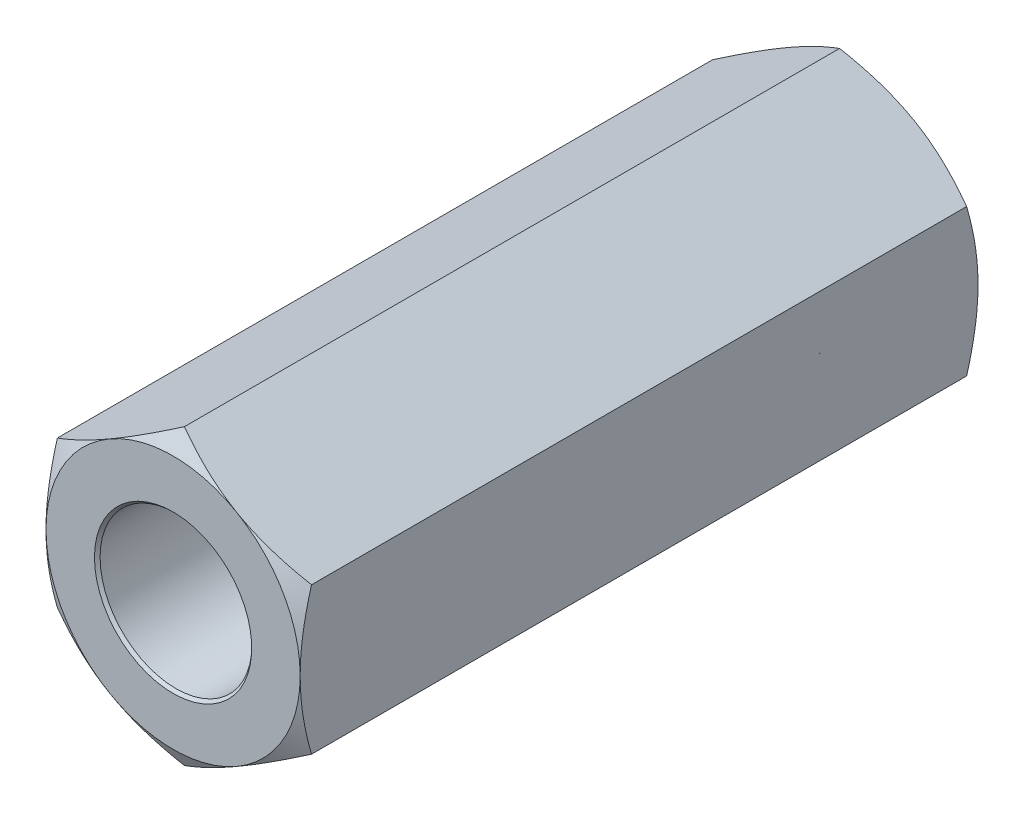
from build123d import *

# Parameters (mm, degrees)
EXTRUDE1_DEPTH          = 6.35
EXTRUDE1_DEPTH_BACK     = 6.35
SKETCH1_R               = 1.4224
SKETCH8_OUTSIDE_W       = 58.916
SKETCH8_OUTSIDE_H       = 59.654
SKETCH8_OUTSIDE_R       = 2.38125
EXTRUDE4_DEPTH          = 14.210632851
EXTRUDE4_DRAFT          = -60
MIRROR1_COPY_1_SKETCH_W = 58.916
MIRROR1_COPY_1_SKETCH_H = 59.654
MIRROR1_COPY_1_SKETCH_R = 2.38125
MIRROR1_COPY_1_DEPTH    = 14.210632851
MIRROR1_COPY_1_DRAFT    = -60


with BuildPart() as part:
    # Sketch1 → Extrude1 (new, two sides: drawn at the far end of the back side and taken through both)
    with BuildSketch(Plane.XY.offset(-EXTRUDE1_DEPTH_BACK)):
        Polygon((0, 2.749630657), (-2.38125, 1.374815329), (-2.38125, -1.374815329), (0, -2.749630657), (2.38125, -1.374815329), (2.38125, 1.374815329), align=None)
        Circle(SKETCH1_R, mode=Mode.SUBTRACT)
    extrude(amount=EXTRUDE1_DEPTH + EXTRUDE1_DEPTH_BACK)

    # Extrude3 cone 1 section (through the dimple's axis) → Extrude3 (revolve, cut)
    with BuildSketch(Plane(origin=(0, 0, -6.35), x_dir=(0, 1, 0), z_dir=(1, 0, 0))):
        Polygon((0, 0), (1.4732, 0), (0, 1.579813584), align=None)
    extrude3 = revolve(axis=Axis((0, 0, -6.35), (0, 0, 1)), mode=Mode.SUBTRACT)


with BuildPart() as extrude4_tool:
    # Sketch8 outside → Extrude4 (with draft: the straight prism first)
    with BuildSketch(Plane(origin=(0, 0, -6.35), x_dir=(-1, 0, 0), z_dir=(0, 0, -1))):
        Rectangle(SKETCH8_OUTSIDE_W, SKETCH8_OUTSIDE_H)
        Circle(SKETCH8_OUTSIDE_R, mode=Mode.SUBTRACT)
    extrude(amount=-EXTRUDE4_DEPTH)
    # Extrude4: the draft: its side faces are tilted about the plane it starts from
    extrude4_sides = [extrude4_tool.faces().sort_by_distance(p)[0] for p in [
        (0, -29.827, 0.755316425),
        (-29.458, 0, 0.755316425),
        (0, 29.827, 0.755316425),
        (29.458, 0, 0.755316425),
        (2.38125, 0, 0.755316425),
    ]]
    draft(extrude4_sides, Plane(origin=(0, 0, -6.35), x_dir=(-1, 0, 0), z_dir=(0, 0, -1)), EXTRUDE4_DRAFT)


with BuildPart() as part_1:
    add(part.part)

    # Extrude4: cut by extrude4_tool
    add(extrude4_tool.part, mode=Mode.SUBTRACT)

    # Mirror1: Extrude3 across plane
    add(extrude3.mirror(Plane.XY), mode=Mode.SUBTRACT)


with BuildPart() as mirror1_copy_1_tool:
    # Mirror1 copy 1 sketch → Mirror1 copy 1 (with draft: the straight prism first)
    with BuildSketch(Plane(origin=(0, 0, 6.35), x_dir=(-1, 0, 0), z_dir=(0, 0, 1))):
        Rectangle(MIRROR1_COPY_1_SKETCH_W, MIRROR1_COPY_1_SKETCH_H)
        Circle(MIRROR1_COPY_1_SKETCH_R, mode=Mode.SUBTRACT)
    extrude(amount=-MIRROR1_COPY_1_DEPTH)
    # Mirror1 copy 1: the draft: its side faces are tilted about the plane it starts from
    mirror1_copy_1_sides = [mirror1_copy_1_tool.faces().sort_by_distance(p)[0] for p in [
        (0, -29.827, -0.755316425),
        (-29.458, 0, -0.755316425),
        (0, 29.827, -0.755316425),
        (29.458, 0, -0.755316425),
        (2.38125, 0, -0.755316425),
    ]]
    draft(mirror1_copy_1_sides, Plane(origin=(0, 0, 6.35), x_dir=(-1, 0, 0), z_dir=(0, 0, 1)), MIRROR1_COPY_1_DRAFT)


with BuildPart() as part_2:
    add(part_1.part)

    # Mirror1 copy 1: cut by mirror1_copy_1_tool
    add(mirror1_copy_1_tool.part, mode=Mode.SUBTRACT)


solid = part_2.part
